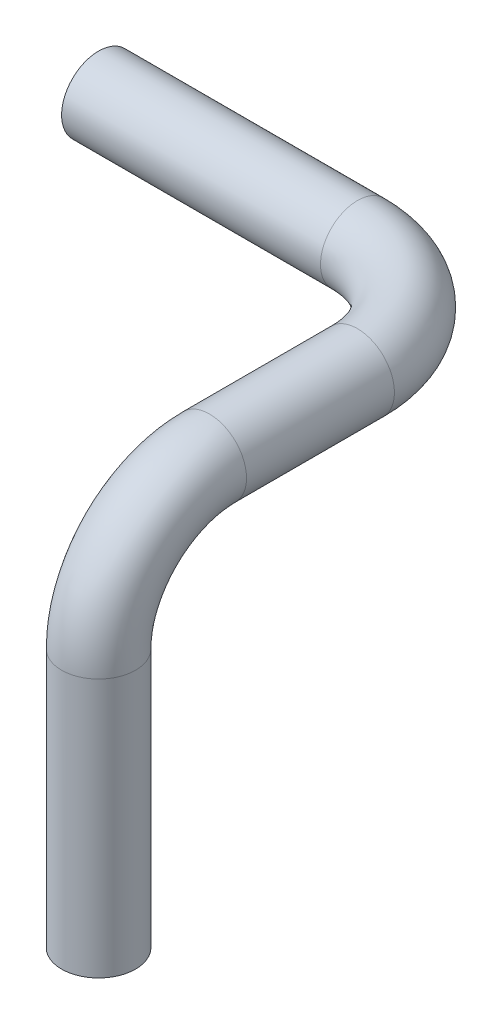
from build123d import *

# Parameters (mm, degrees)
SWEEP1_PROFILE_R = 25.4
SHELL1_T         = -2.54


with BuildPart() as part:
    # Sweep1: sweep along a curve in space
    with BuildLine() as sweep1_path:
        Line((0, 254, 0), (177.8, 254, 0))
        ThreePointArc((254, 254, 76.2), (231.681536726, 254, 22.318463274), (177.8, 254, 0))
        Line((254, 254, 76.2), (254, 254, 177.8))
        ThreePointArc((254, 177.8, 254), (254, 231.681536726, 231.681536726), (254, 254, 177.8))
        Line((254, 177.8, 254), (254, 0, 254))
    # Sweep1 profile (on start of the path) → Sweep1 (sweep)
    with BuildSketch(Plane(origin=(0, 254, 0), x_dir=(0, 0, 1), z_dir=(1, 0, 0))):
        Circle(SWEEP1_PROFILE_R)
    sweep(path=sweep1_path.line)

    # Shell1
    shell1_openings = [part.faces().sort_by_distance(p)[0] for p in [
        (254, 0, 254),
        (0, 254, 0),
    ]]
    offset(amount=SHELL1_T, openings=shell1_openings, kind=Kind.INTERSECTION)


solid = part.part
